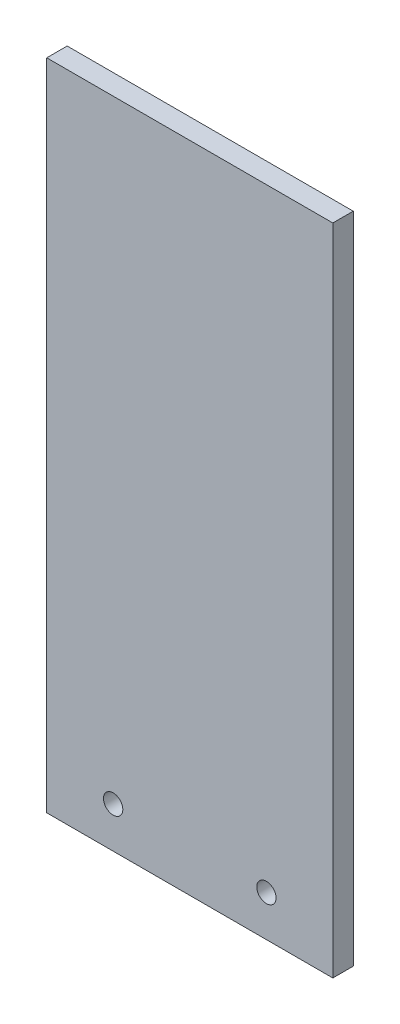
from build123d import *

# Parameters (mm, degrees)
SKETCH1_W                    = 88.9
SKETCH1_H                    = 6.35
BOSS_EXTRUDE1_DEPTH          = 203.2
F_6_0_6_DIAMETER_HOLE1_D     = 6
F_6_0_6_DIAMETER_HOLE1_DEPTH = 6.35


with BuildPart() as part:
    # Sketch1 → Boss-Extrude1 (new body)
    with BuildSketch(Plane(origin=(0, 0, 0), x_dir=(1, 0, 0), z_dir=(0, 1, 0))):
        with Locations((44.45, 3.175)):
            Rectangle(SKETCH1_W, SKETCH1_H)
    extrude(amount=BOSS_EXTRUDE1_DEPTH)

    # Ø6.0 (6) Diameter Hole1
    with Locations(Plane(origin=(0, 0, -6.35), x_dir=(-1, 0, 0), z_dir=(0, 0, -1))):
        with Locations((-20.6375, 12.7), (-68.2625, 12.7)):
            Hole(F_6_0_6_DIAMETER_HOLE1_D / 2, depth=F_6_0_6_DIAMETER_HOLE1_DEPTH)


solid = part.part
